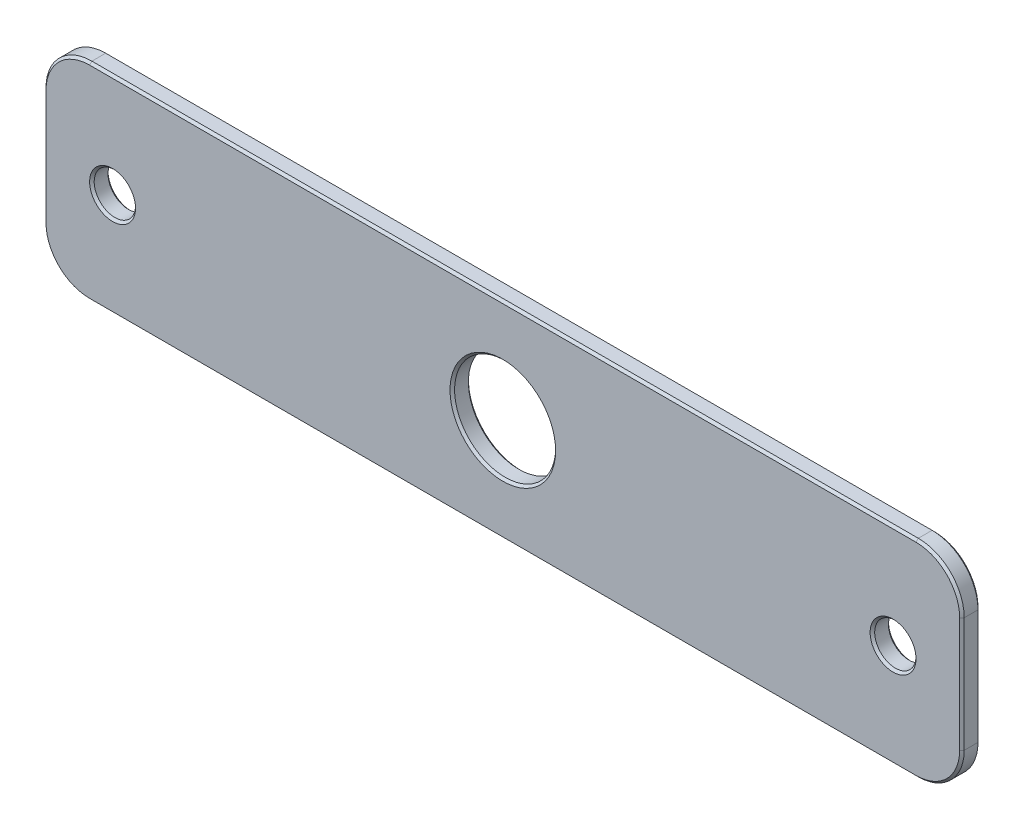
from build123d import *

# Parameters (mm, degrees)
ESQUISSE1_W        = 200
ESQUISSE1_H        = 45
BOSS_EXTRU_1_DEPTH = 4
CONG_2_R           = 10
D_GAGEMENT_M81_D   = 9
D_GAGEMENT_M201_D  = 22
CHANFREIN2_SIZE    = 0.5
CHANFREIN3_SIZE    = 0.5


with BuildPart() as part:
    # Esquisse1 → Boss.-Extru.1 (new body)
    with BuildSketch(Plane.XY):
        with Locations((-21.919003271, 59.078947368)):
            Rectangle(ESQUISSE1_W, ESQUISSE1_H)
    extrude(amount=BOSS_EXTRU_1_DEPTH)

    # Congé2
    cong_2_edges = [part.edges().sort_by_distance(p)[0] for p in [
        (-121.919003271, 81.578947368, 2),
        (78.080996729, 81.578947368, 2),
        (78.080996729, 36.578947368, 2),
        (-121.919003271, 36.578947368, 2),
    ]]
    fillet(cong_2_edges, radius=CONG_2_R)

    # Dégagement M81 (through all)
    with Locations(Plane.XY.offset(4)):
        with Locations((-106.919003271, 59.078947368), (63.080996729, 59.078947368)):
            Hole(D_GAGEMENT_M81_D / 2)

    # Dégagement M201 (through all)
    with Locations(Plane.XY.offset(4)):
        with Locations((-21.919003271, 59.078947368)):
            Hole(D_GAGEMENT_M201_D / 2)

    # Chanfrein2
    chanfrein2_edges = [part.edges().sort_by_distance(p)[0] for p in [
        (-121.919003271, 59.078947368, 0),
        (-121.919003271, 59.078947368, 4),
        (-21.919003271, 81.578947368, 0),
        (78.080996729, 59.078947368, 0),
        (-21.919003271, 36.578947368, 0),
        (75.15206454, 78.65001518, 0),
        (75.15206454, 39.507879557, 0),
        (-118.990071083, 39.507879557, 0),
        (-118.990071083, 78.65001518, 0),
        (-21.919003271, 81.578947368, 4),
        (-21.919003271, 36.578947368, 4),
        (78.080996729, 59.078947368, 4),
        (75.15206454, 78.65001518, 4),
        (75.15206454, 39.507879557, 4),
        (-118.990071083, 39.507879557, 4),
        (-118.990071083, 78.65001518, 4),
    ]]
    chamfer(chanfrein2_edges, length=CHANFREIN2_SIZE)

    # Chanfrein3
    chanfrein3_edges = [part.edges().sort_by_distance(p)[0] for p in [
        (67.580996729, 59.078947368, 4),
        (67.580996729, 59.078947368, 0),
        (-102.419003271, 59.078947368, 4),
        (-102.419003271, 59.078947368, 0),
        (-10.919003271, 59.078947368, 4),
        (-10.919003271, 59.078947368, 0),
    ]]
    chamfer(chanfrein3_edges, length=CHANFREIN3_SIZE)


solid = part.part
